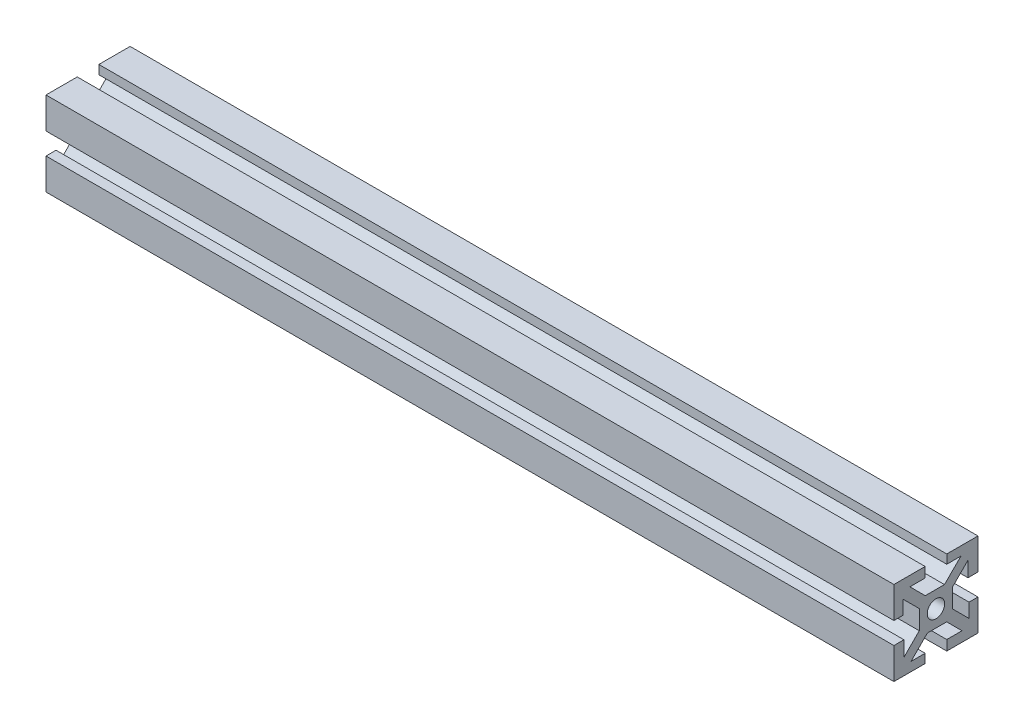
from build123d import *

# Parameters (mm, degrees)
SKETCH1_R           = 2.605
BOSS_EXTRUDE1_DEPTH = 254
CIRPATTERN1_COUNT   = 4


with BuildPart() as part:
    # Sketch1 → Boss-Extrude1 (new body)
    with BuildSketch(Plane(origin=(0, 0, 0), x_dir=(0, 0, -1), z_dir=(1, 0, 0))):
        Polygon((5, -5), (5, 3.203948776), (9.596194078, 7.800142853), (9.596194078, 3.24), (12.596194078, 3.24), (12.596194078, 12.596194078), (3.24, 12.596194078), (3.24, 9.921463197), (7.474873734, 9.921463197), (2.553410537, 5), (-5, 5), (-5, -5), align=None)
        Circle(SKETCH1_R, mode=Mode.SUBTRACT)
    boss_extrude1 = extrude(amount=BOSS_EXTRUDE1_DEPTH)

    # CirPattern1: Boss-Extrude1 ×4 about axis
    cirpattern1_axis = Axis((0, 0, 0), (1, 0, 0))
    for i in range(1, CIRPATTERN1_COUNT):
        add(boss_extrude1.rotate(cirpattern1_axis, i * 360 / CIRPATTERN1_COUNT))


solid = part.part
